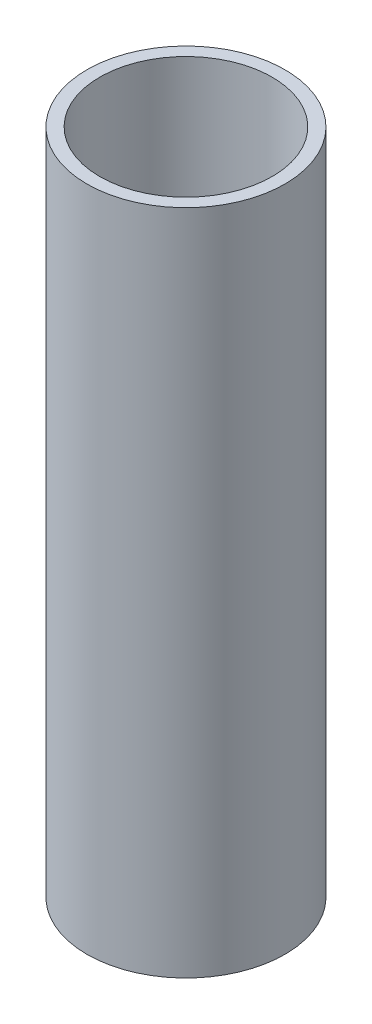
from build123d import *

# Parameters (mm, degrees)
SKETCH1_R           = 30.1625
SKETCH1_R_2         = 26.2509
BOSS_EXTRUDE1_DEPTH = 203.2


with BuildPart() as part:
    # Sketch1 → Boss-Extrude1 (new body)
    with BuildSketch(Plane(origin=(0, 0, 0), x_dir=(1, 0, 0), z_dir=(0, 1, 0))):
        Circle(SKETCH1_R)
        Circle(SKETCH1_R_2, mode=Mode.SUBTRACT)
    extrude(amount=BOSS_EXTRUDE1_DEPTH)


solid = part.part
